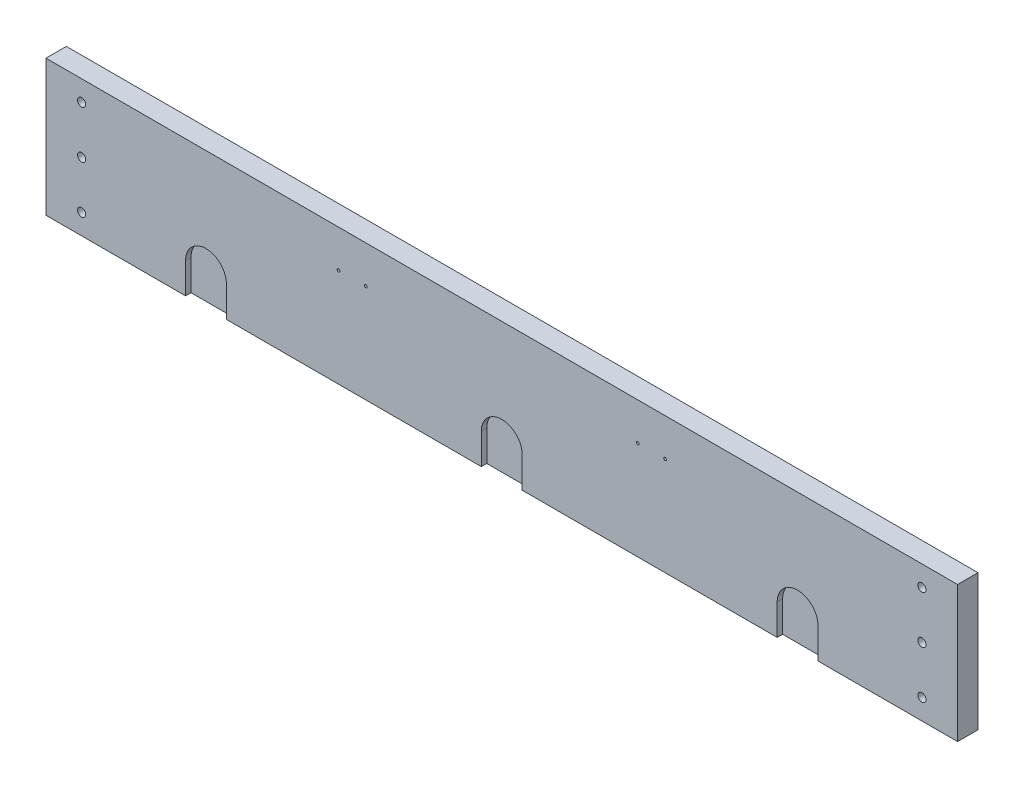
from build123d import *

# Parameters (mm, degrees)
SKETCH1_W           = 812.8
SKETCH1_H           = 19.05
SKETCH1_W_2         = 19.05
BOSS_EXTRUDE2_DEPTH = 127
SKETCH2_R           = 3.81
CUT_EXTRUDE1_DEPTH  = 19.05
SKETCH3_R           = 19.05
CUT_EXTRUDE2_DEPTH  = 19.05
BOSS_EXTRUDE3_DEPTH = 13.97
SKETCH5_R           = 1.27
CUT_EXTRUDE3_DEPTH  = 19.05


with BuildPart() as part:
    # Sketch1 → Boss-Extrude2 (new body)
    with BuildSketch(Plane(origin=(0, 0, 0), x_dir=(1, 0, 0), z_dir=(0, 1, 0))):
        with Locations((406.4, -9.525)):
            Rectangle(SKETCH1_W, SKETCH1_H)
        with Locations((822.325, -9.525)):
            Rectangle(SKETCH1_W_2, SKETCH1_H)
        with Locations((-9.525, -9.525)):
            Rectangle(SKETCH1_W_2, SKETCH1_H)
    extrude(amount=BOSS_EXTRUDE2_DEPTH)

    # Sketch2 → Cut-Extrude1 (cut)
    with BuildSketch(Plane(origin=(0, 0, 0), x_dir=(-1, 0, 0), z_dir=(0, 0, -1))):
        with Locations((-14.224, 107.95)):
            Circle(SKETCH2_R)
        with Locations((-14.224, 63.5)):
            Circle(SKETCH2_R)
        with Locations((-14.224, 19.05)):
            Circle(SKETCH2_R)
        with Locations((-798.576, 19.05)):
            Circle(SKETCH2_R)
        with Locations((-798.576, 107.95)):
            Circle(SKETCH2_R)
        with Locations((-798.576, 63.5)):
            Circle(SKETCH2_R)
    extrude(amount=-CUT_EXTRUDE1_DEPTH, mode=Mode.SUBTRACT)

    # Sketch3 → Cut-Extrude2 (cut)
    with BuildSketch(Plane(origin=(0, 0, 0), x_dir=(-1, 0, 0), z_dir=(0, 0, -1))):
        with BuildLine():
            ThreePointArc((-663.448, 28.702), (-682.498, 9.652), (-701.548, 28.702))
            Line((-701.548, 28.702), (-701.548, 0))
            Line((-701.548, 0), (-663.448, 0))
            Line((-663.448, 0), (-663.448, 28.702))
        make_face()
        with Locations((-682.498, 28.702)):
            Circle(SKETCH3_R)
        with Locations((-406.4, 28.702)):
            Circle(SKETCH3_R)
        with BuildLine():
            Line((-425.45, 28.702), (-425.45, 0))
            Line((-425.45, 0), (-387.35, 0))
            Line((-387.35, 0), (-387.35, 28.702))
            ThreePointArc((-387.35, 28.702), (-406.4, 9.652), (-425.45, 28.702))
        make_face()
        with BuildLine():
            Line((-149.352, 28.702), (-149.352, 0))
            Line((-149.352, 0), (-111.252, 0))
            Line((-111.252, 0), (-111.252, 28.702))
            ThreePointArc((-111.252, 28.702), (-130.302, 9.652), (-149.352, 28.702))
        make_face()
        with Locations((-130.302, 28.702)):
            Circle(SKETCH3_R)
    extrude(amount=-CUT_EXTRUDE2_DEPTH, mode=Mode.SUBTRACT)

    # Sketch4 → Boss-Extrude3 (add)
    with BuildSketch(Plane(origin=(0, 0, 0), x_dir=(-1, 0, 0), z_dir=(0, 0, -1))):
        with BuildLine():
            ThreePointArc((-387.35, 28.702), (-406.4, 9.652), (-425.45, 28.702))
            Line((-425.45, 28.702), (-425.45, 0))
            Line((-425.45, 0), (-387.35, 0))
            Line((-387.35, 0), (-387.35, 28.702))
        make_face()
        with BuildLine():
            ThreePointArc((-387.35, 28.702), (-406.4, 47.752), (-425.45, 28.702))
            ThreePointArc((-425.45, 28.702), (-406.4, 9.652), (-387.35, 28.702))
        make_face()
        with BuildLine():
            Line((-111.252, 0), (-111.252, 28.702))
            ThreePointArc((-111.252, 28.702), (-130.302, 9.652), (-149.352, 28.702))
            Line((-149.352, 28.702), (-149.352, 0))
            Line((-149.352, 0), (-111.252, 0))
        make_face()
        with BuildLine():
            ThreePointArc((-149.352, 28.702), (-130.302, 9.652), (-111.252, 28.702))
            ThreePointArc((-111.252, 28.702), (-130.302, 47.752), (-149.352, 28.702))
        make_face()
        with BuildLine():
            Line((-663.448, 0), (-663.448, 28.702))
            ThreePointArc((-663.448, 28.702), (-682.498, 9.652), (-701.548, 28.702))
            Line((-701.548, 28.702), (-701.548, 0))
            Line((-701.548, 0), (-663.448, 0))
        make_face()
        with BuildLine():
            ThreePointArc((-701.548, 28.702), (-682.498, 9.652), (-663.448, 28.702))
            ThreePointArc((-663.448, 28.702), (-682.498, 47.752), (-701.548, 28.702))
        make_face()
    extrude(amount=-BOSS_EXTRUDE3_DEPTH)

    # Sketch5 → Cut-Extrude3 (cut)
    with BuildSketch(Plane.XY.offset(19.05)):
        with Locations((254, 91.948)):
            Circle(SKETCH5_R)
        with Locations((279.4, 91.948)):
            Circle(SKETCH5_R)
        with Locations((533.4, 91.948)):
            Circle(SKETCH5_R)
        with Locations((558.8, 91.948)):
            Circle(SKETCH5_R)
    extrude(amount=-CUT_EXTRUDE3_DEPTH, mode=Mode.SUBTRACT)


solid = part.part
